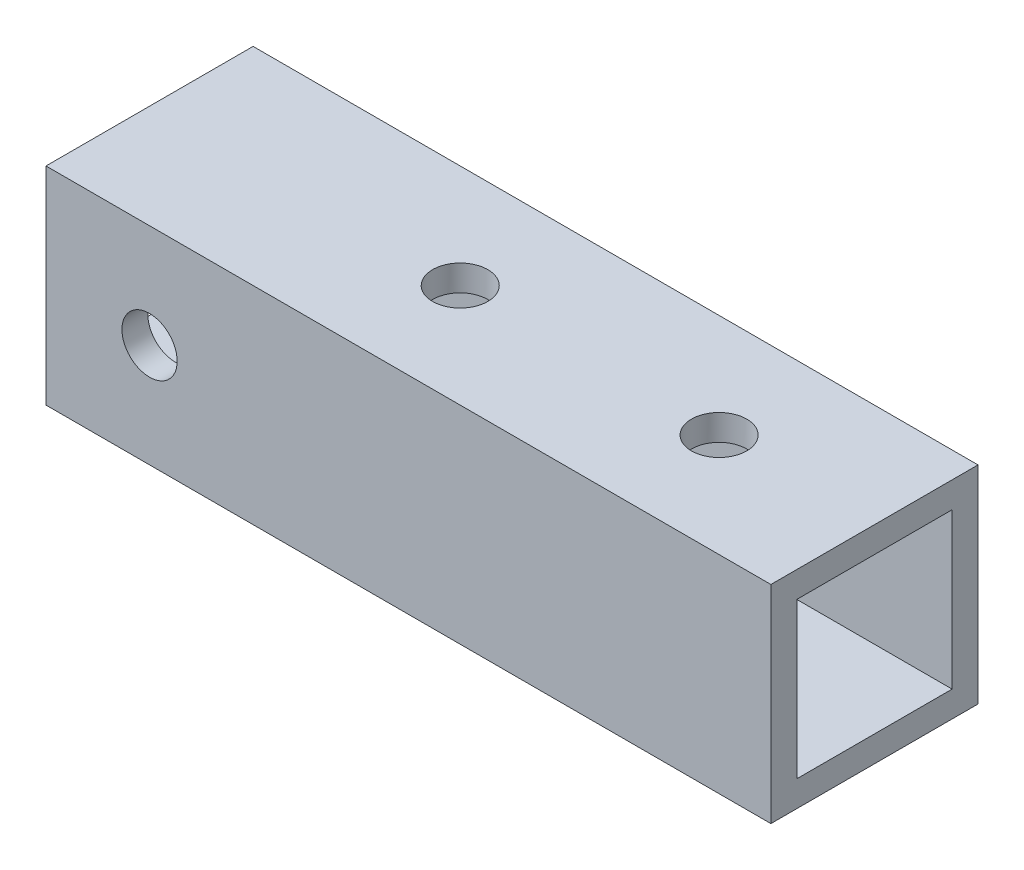
from build123d import *

# Parameters (mm, degrees)
SKETCH_1_W          = 12
SKETCH_1_H          = 12
SKETCH_1_W_2        = 9
SKETCH_1_H_2        = 9
EXTRUDE_1_DEPTH     = 21
SKETCH_4_R          = 1.6
CUT_EXTRUDE_3_DEPTH = 13
SKETCH_5_R          = 1.6
CUT_EXTRUDE_4_DEPTH = 13


with BuildPart() as part:
    # ｽｹｯﾁ1 → ﾎﾞｽ - 押し出し1 (new body, symmetric)
    with BuildSketch(Plane(origin=(0, 0, 0), x_dir=(0, 0, -1), z_dir=(1, 0, 0))):
        Rectangle(SKETCH_1_W, SKETCH_1_H)
        Rectangle(SKETCH_1_W_2, SKETCH_1_H_2, mode=Mode.SUBTRACT)
    extrude(amount=EXTRUDE_1_DEPTH, both=True)

    # ｽｹｯﾁ4 → ｶｯﾄ - 押し出し3 (cut, through all)
    with BuildSketch(Plane(origin=(0, 6, 0), x_dir=(1, 0, 0), z_dir=(0, 1, 0))):
        with Locations((-3, 0)):
            Circle(SKETCH_4_R)
        with Locations((12, 0)):
            Circle(SKETCH_4_R)
    extrude(amount=-CUT_EXTRUDE_3_DEPTH, mode=Mode.SUBTRACT)

    # ｽｹｯﾁ5 → ｶｯﾄ - 押し出し4 (cut, through all)
    with BuildSketch(Plane.XY.offset(6)):
        with Locations((-15, 0)):
            Circle(SKETCH_5_R)
    extrude(amount=-CUT_EXTRUDE_4_DEPTH, mode=Mode.SUBTRACT)


solid = part.part
